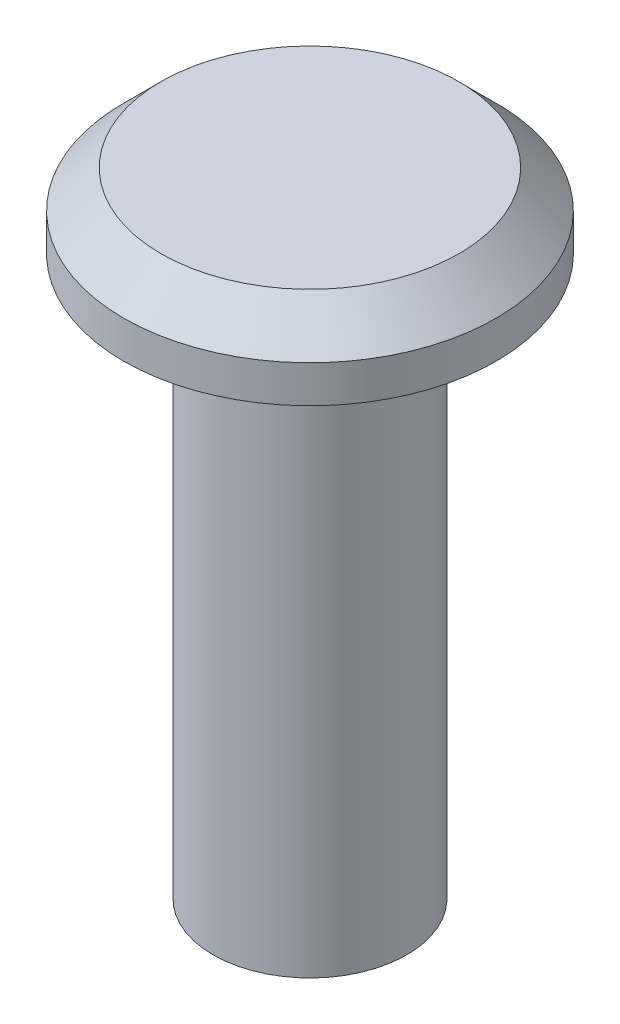
from build123d import *

# Parameters (mm, degrees)
SKETCH1_R           = 2.6
BOSS_EXTRUDE1_DEPTH = 15
SKETCH2_R           = 5
BOSS_EXTRUDE2_DEPTH = 2
CHAMFER1_SIZE       = 1.2
CHAMFER2_SIZE       = 1


with BuildPart() as part:
    # Sketch1 → Boss-Extrude1 (new body)
    with BuildSketch(Plane(origin=(0, 0, 0), x_dir=(1, 0, 0), z_dir=(0, 1, 0))):
        Circle(SKETCH1_R)
    extrude(amount=BOSS_EXTRUDE1_DEPTH)

    # Sketch2 → Boss-Extrude2 (add)
    with BuildSketch(Plane(origin=(0, 15, 0), x_dir=(1, 0, 0), z_dir=(0, 1, 0))):
        Circle(SKETCH2_R)
    extrude(amount=BOSS_EXTRUDE2_DEPTH)

    # Chamfer1
    chamfer1_edges = [part.edges().sort_by_distance(p)[0] for p in [
        (-2.6, 15, 0),
    ]]
    chamfer(chamfer1_edges, length=CHAMFER1_SIZE)

    # Chamfer2
    chamfer2_edges = [part.edges().sort_by_distance(p)[0] for p in [
        (-5, 17, 0),
    ]]
    chamfer(chamfer2_edges, length=CHAMFER2_SIZE)


solid = part.part
